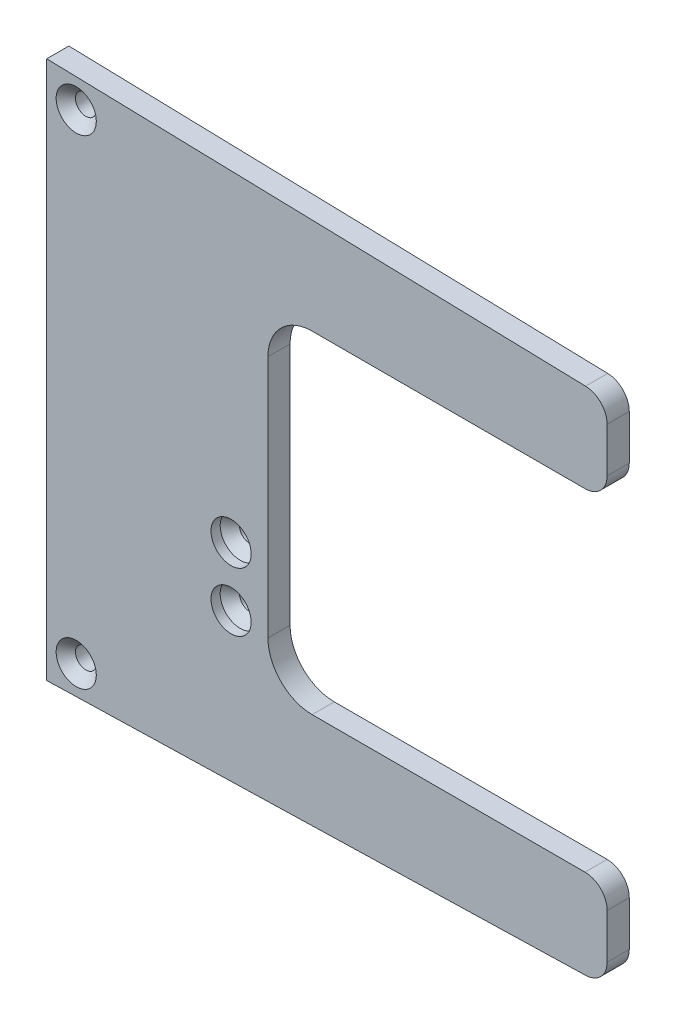
from build123d import *

# Parameters (mm, degrees)
SKETCH1_W                                       = 95.25
SKETCH1_H                                       = 231.8385
EXTRUDE1_DEPTH                                  = 9.525
CSK_FOR_M8_FLAT_HEAD_MACHINE_SCREW1_AT_2_COUNT  = 2
CSK_FOR_M8_FLAT_HEAD_MACHINE_SCREW1_AT_2_PITCH  = 25.4
CSK_FOR_M8_FLAT_HEAD_MACHINE_SCREW2_D           = 9
CSK_FOR_M8_FLAT_HEAD_MACHINE_SCREW2_CSINK_D     = 17.3
CSK_FOR_M8_FLAT_HEAD_MACHINE_SCREW2_CSINK_ANGLE = 90
CUT_EXTRUDE1_REACH                              = 11.525
BOSS_EXTRUDE1_DEPTH                             = 9.525
FILLET1_R                                       = 9.525
FILLET2_R                                       = 19.05


with BuildPart() as part:
    # Sketch1 → Extrude1 (new body)
    with BuildSketch(Plane.XY):
        Rectangle(SKETCH1_W, SKETCH1_H)
    extrude(amount=EXTRUDE1_DEPTH)

    # Sketch2 → CSK for M8 Flat Head Machine Screw1 (revolve, cut)
    with BuildSketch(Plane(origin=(31.75, -50.15865, 9.525), x_dir=(0, -1, 0), z_dir=(1, 0, 0))):
        Polygon((0, 0), (0, 9.525), (4.5, 9.525), (4.5, 8.1124), (8.65, 3.9624), (8.65, 0), align=None)
    csk_for_m8_flat_head_machine_screw1 = revolve(axis=Axis((31.75, -50.15865, 15.875), (0, 0, -1)), mode=Mode.SUBTRACT)

    # CSK for M8 Flat Head Machine Screw1 at 2: CSK for M8 Flat Head Machine Screw1 ×2
    with Locations(*[(0, i * CSK_FOR_M8_FLAT_HEAD_MACHINE_SCREW1_AT_2_PITCH, 0) for i in range(1, CSK_FOR_M8_FLAT_HEAD_MACHINE_SCREW1_AT_2_COUNT)]):
        add(csk_for_m8_flat_head_machine_screw1, mode=Mode.SUBTRACT)

    # CSK for M8 Flat Head Machine Screw2 (through all)
    with Locations(Plane.XY.offset(9.525)):
        with Locations((-34.925, 103.21925), (-34.925, -103.21925)):
            CounterSinkHole(CSK_FOR_M8_FLAT_HEAD_MACHINE_SCREW2_D / 2, CSK_FOR_M8_FLAT_HEAD_MACHINE_SCREW2_CSINK_D / 2, counter_sink_angle=CSK_FOR_M8_FLAT_HEAD_MACHINE_SCREW2_CSINK_ANGLE)

    # Sketch11 → Cut-Extrude1 (cut, up to next)
    with BuildSketch(Plane.XY.offset(9.525), mode=Mode.PRIVATE) as cut_extrude1_sk1:
        Polygon((-47.625, 115.91925), (47.625, 113.425040971), (47.625, 115.91925), align=None)
    cut_extrude1_tool1 = extrude(cut_extrude1_sk1.sketch, amount=-CUT_EXTRUDE1_REACH, mode=Mode.PRIVATE) & part.part
    add(cut_extrude1_tool1.solids().sort_by_distance((15.875, 115.087847, 9.525))[0], mode=Mode.SUBTRACT)
    # Sketch11 → Cut-Extrude1 (cut, up to next)
    with BuildSketch(Plane.XY.offset(9.525), mode=Mode.PRIVATE) as cut_extrude1_sk2:
        Polygon((-47.625, -115.91925), (47.625, -115.91925), (47.625, -113.425040971), align=None)
    cut_extrude1_tool2 = extrude(cut_extrude1_sk2.sketch, amount=-CUT_EXTRUDE1_REACH, mode=Mode.PRIVATE) & part.part
    add(cut_extrude1_tool2.solids().sort_by_distance((15.875, -115.087847, 9.525))[0], mode=Mode.SUBTRACT)

    # Sketch12 → Boss-Extrude1 (add)
    with BuildSketch(Plane.XY.offset(9.525)):
        Polygon((47.625, 113.425040971), (193.675, 109.600587125), (193.675, 71.500587125), (47.625, 71.500587125), align=None)
        Polygon((47.625, -71.500587125), (193.675, -71.500587125), (193.675, -109.600587125), (47.625, -113.425040971), align=None)
    extrude(amount=-BOSS_EXTRUDE1_DEPTH)

    # Fillet1
    fillet1_edges = [part.edges().sort_by_distance(p)[0] for p in [
        (193.675, 109.600587125, 4.7625),
        (193.675, 71.500587125, 4.7625),
        (193.675, -71.500587125, 4.7625),
        (193.675, -109.600587125, 4.7625),
    ]]
    fillet(fillet1_edges, radius=FILLET1_R)

    # Fillet2
    fillet2_edges = [part.edges().sort_by_distance(p)[0] for p in [
        (47.625, 71.500587125, 4.7625),
        (47.625, -71.500587125, 4.7625),
    ]]
    fillet(fillet2_edges, radius=FILLET2_R)


solid = part.part
